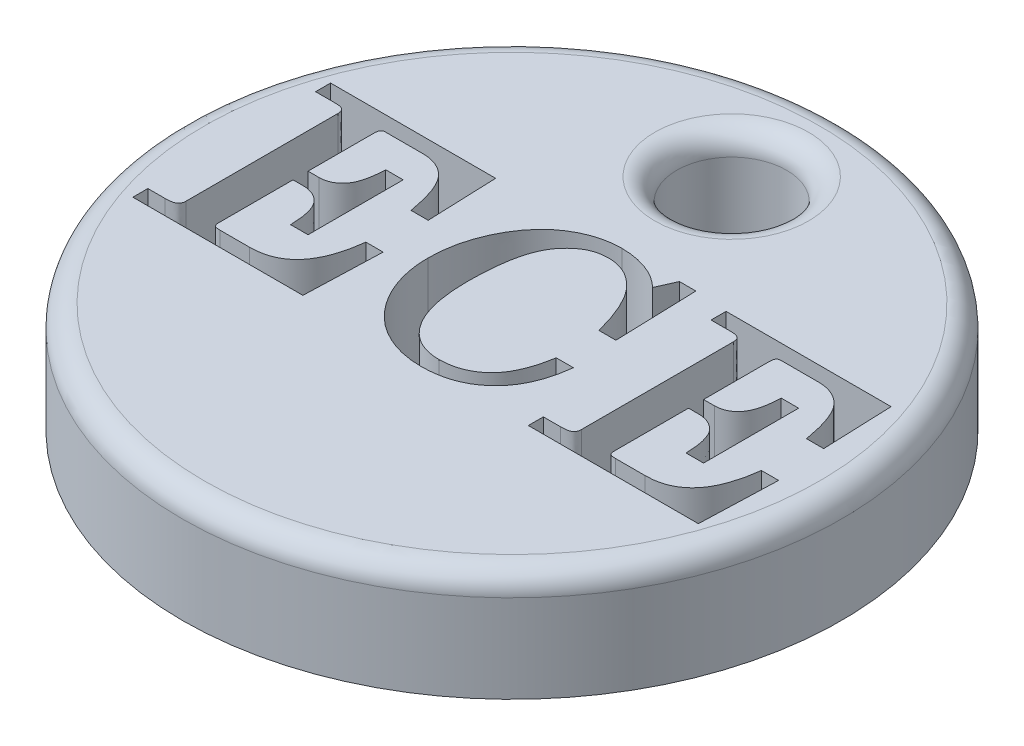
from build123d import *

# Parameters (mm, degrees)
SKETCH1_R           = 15
SKETCH1_R_2         = 2.5
BOSS_EXTRUDE1_DEPTH = 4
SKETCH2_R           = 15
SKETCH2_R_2         = 2.5
BOSS_EXTRUDE2_DEPTH = 1
FILLET1_R           = 1


with BuildPart() as part:
    # Sketch1 → Boss-Extrude1 (new body)
    with BuildSketch(Plane(origin=(0, 0, 0), x_dir=(1, 0, 0), z_dir=(0, 1, 0))):
        Circle(SKETCH1_R)
        with Locations((0, 10)):
            Circle(SKETCH1_R_2, mode=Mode.SUBTRACT)
        with BuildLine():
            Line((-12.816455696, 4.559282851), (-5.304588608, 4.559282851))
            Line((-5.304588608, 4.559282851), (-5.183544304, 1.369409433))
            Line((-5.183544304, 1.369409433), (-5.964992089, 1.369409433))
            add(Edge.make_bspline(
                [(-5.964992089, 1.369409433), (-5.986281307, 1.485829278), (-6.027251179, 1.709872544), (-6.09691097, 2.03065438), (-6.178132694, 2.321858437), (-6.262578433, 2.585270441), (-6.360705102, 2.817779205), (-6.459727152, 3.023988235), (-6.570656541, 3.199818347), (-6.689291162, 3.348294343), (-6.817301446, 3.473270548), (-6.951038881, 3.582226232), (-7.096552563, 3.671938194), (-7.248723792, 3.747265164), (-7.411675737, 3.803812372), (-7.581643533, 3.847718892), (-7.762280373, 3.869850654), (-7.885038619, 3.873742839), (-7.947982595, 3.875738547)],
                knots=[0, 0, 0, 0, 0.000355055, 0.000683282, 0.000984286, 0.001261799, 0.001512378, 0.001740851, 0.001947277, 0.002134649, 0.002309612, 0.002483084, 0.002651015, 0.002821381, 0.002991412, 0.003167557, 0.003347061, 0.003535958, 0.003535958, 0.003535958, 0.003535958], degree=3))
            Line((-7.947982595, 3.875738547), (-9.662183544, 3.875738547))
            add(Edge.make_bspline(
                [(-9.662183544, 3.875738547), (-9.686590299, 3.873079058), (-9.737084073, 3.867576989), (-9.79187547, 3.825290825), (-9.825309008, 3.77193289), (-9.843197408, 3.710763238), (-9.852838206, 3.631011988), (-9.853863138, 3.571978347), (-9.85443038, 3.539306585)],
                knots=[0, 0, 0, 0, 7.2613e-05, 0.000150224, 0.000196643, 0.000260253, 0.000339301, 0.000437269, 0.000437269, 0.000437269, 0.000437269], degree=3))
            Line((-9.85443038, 3.539306585), (-9.85443038, 0.571941079))
            Line((-9.85443038, 0.571941079), (-9.361352848, 0.571941079))
            add(Edge.make_bspline(
                [(-9.361352848, 0.571941079), (-9.318583098, 0.573595492), (-9.234461221, 0.576849482), (-9.111162234, 0.593963395), (-8.993863335, 0.626323435), (-8.884033689, 0.673274803), (-8.778673677, 0.730345716), (-8.680915787, 0.802613326), (-8.588042471, 0.88626065), (-8.501369299, 0.983641568), (-8.422640676, 1.09682009), (-8.352445274, 1.227900491), (-8.29573087, 1.378846708), (-8.242476792, 1.545755817), (-8.205719241, 1.732948279), (-8.172686978, 1.936972787), (-8.152229688, 2.160011542), (-8.145498883, 2.314589472), (-8.142009494, 2.394725889)],
                knots=[0, 0, 0, 0, 0.000128362, 0.00025247, 0.000372528, 0.000492204, 0.000610119, 0.000731176, 0.000855946, 0.000984554, 0.001121342, 0.001268668, 0.001429318, 0.001604426, 0.001793649, 0.002000849, 0.00222438, 0.002465011, 0.002465011, 0.002465011, 0.002465011], degree=3))
            Line((-8.142009494, 2.394725889), (-7.348101266, 2.394725889))
            Line((-7.348101266, 2.394725889), (-7.348101266, -1.934388035))
            Line((-7.348101266, -1.934388035), (-8.142009494, -1.934388035))
            add(Edge.make_bspline(
                [(-8.142009494, -1.934388035), (-8.145486425, -1.850690613), (-8.152178707, -1.689592614), (-8.172633195, -1.458277906), (-8.205193707, -1.247469079), (-8.24418684, -1.057083799), (-8.296876455, -0.887752558), (-8.356286349, -0.738271818), (-8.424893398, -0.607794818), (-8.507041219, -0.500028728), (-8.595368486, -0.407272558), (-8.692551734, -0.329087092), (-8.795830639, -0.26086641), (-8.906633017, -0.204893452), (-9.025654625, -0.164593005), (-9.151322342, -0.134338038), (-9.284720067, -0.113556793), (-9.376699046, -0.112263475), (-9.423655063, -0.111603225)],
                knots=[0, 0, 0, 0, 0.000251298, 0.00048369, 0.000696167, 0.000890985, 0.001066093, 0.001227402, 0.001373161, 0.001506666, 0.00163256, 0.001756553, 0.001879982, 0.002003373, 0.002127786, 0.002256013, 0.002390946, 0.002531672, 0.002531672, 0.002531672, 0.002531672], degree=3))
            Line((-9.423655063, -0.111603225), (-9.85443038, -0.111603225))
            Line((-9.85443038, -0.111603225), (-9.85443038, -3.479482972))
            add(Edge.make_bspline(
                [(-9.85443038, -3.479482972), (-9.854381112, -3.50574702), (-9.854290593, -3.554001322), (-9.838365834, -3.618020738), (-9.821636658, -3.671107598), (-9.787878561, -3.708056504), (-9.742813823, -3.732221482), (-9.684974169, -3.7469717), (-9.613168799, -3.755068374), (-9.560744488, -3.756431597), (-9.532238924, -3.757172845)],
                knots=[0, 0, 0, 0, 7.8404e-05, 0.000144049, 0.000197599, 0.000242982, 0.000290011, 0.000349183, 0.000420939, 0.000506457, 0.000506457, 0.000506457, 0.000506457], degree=3))
            Line((-9.532238924, -3.757172845), (-8.179390823, -3.757172845))
            add(Edge.make_bspline(
                [(-8.179390823, -3.757172845), (-8.093820738, -3.755405593), (-7.92672034, -3.75195452), (-7.683560133, -3.716779904), (-7.453538807, -3.662313942), (-7.237993715, -3.583902551), (-7.035823491, -3.483354545), (-6.848551686, -3.359142306), (-6.672461464, -3.215322738), (-6.514171578, -3.045304637), (-6.366924413, -2.856023595), (-6.235681121, -2.643037993), (-6.118228598, -2.407990645), (-6.012943956, -2.15190931), (-5.924840371, -1.872157778), (-5.849132979, -1.571285989), (-5.783475169, -1.2484377), (-5.755241294, -1.024416559), (-5.740704114, -0.90907158)],
                knots=[0, 0, 0, 0, 0.000256552, 0.000500991, 0.000735426, 0.000964612, 0.001187512, 0.001411163, 0.001637483, 0.00186791, 0.002106465, 0.002355909, 0.002617021, 0.002894031, 0.003185636, 0.003496051, 0.003824554, 0.004173215, 0.004173215, 0.004173215, 0.004173215], degree=3))
            Line((-5.740704114, -0.90907158), (-4.955696203, -0.90907158))
            Line((-4.955696203, -0.90907158), (-5.076740506, -4.440717149))
            Line((-5.076740506, -4.440717149), (-12.816455696, -4.440717149))
            Line((-12.816455696, -4.440717149), (-12.816455696, -3.757172845))
            Line((-12.816455696, -3.757172845), (-12.038568038, -3.757172845))
            add(Edge.make_bspline(
                [(-12.038568038, -3.757172845), (-11.985118982, -3.756473559), (-11.886759814, -3.755186702), (-11.753911012, -3.738537224), (-11.649119675, -3.710930668), (-11.568974594, -3.67243269), (-11.514731814, -3.616493802), (-11.476958428, -3.552979196), (-11.452127266, -3.478862951), (-11.450321619, -3.425702573), (-11.449367089, -3.397600061)],
                knots=[0, 0, 0, 0, 0.000160295, 0.000294981, 0.000400366, 0.000484764, 0.000557769, 0.000630425, 0.000705293, 0.000789259, 0.000789259, 0.000789259, 0.000789259], degree=3))
            Line((-11.449367089, -3.397600061), (-11.449367089, 3.533966395))
            add(Edge.make_bspline(
                [(-11.449367089, 3.533966395), (-11.450938449, 3.56133357), (-11.453912967, 3.613138472), (-11.470496787, 3.686102732), (-11.503361955, 3.746902252), (-11.550862663, 3.79569976), (-11.613347248, 3.834241454), (-11.695492555, 3.857523729), (-11.794661361, 3.873421993), (-11.867598111, 3.874928134), (-11.906843354, 3.875738547)],
                knots=[0, 0, 0, 0, 8.2192e-05, 0.000155586, 0.000222498, 0.000286704, 0.00035784, 0.000440032, 0.000540994, 0.0006586, 0.0006586, 0.0006586, 0.0006586], degree=3))
            Line((-11.906843354, 3.875738547), (-12.816455696, 3.875738547))
            Line((-12.816455696, 3.875738547), (-12.816455696, 4.559282851))
        make_face(mode=Mode.SUBTRACT)
        with BuildLine():
            Line((2.570411392, 3.829456901), (2.94778481, 4.673206901))
            Line((2.94778481, 4.673206901), (3.695411392, 4.673206901))
            Line((3.695411392, 4.673206901), (3.816455696, 0.913713231))
            Line((3.816455696, 0.913713231), (3.043908228, 0.913713231))
            add(Edge.make_bspline(
                [(3.043908228, 0.913713231), (3.009497834, 1.037889271), (2.942713098, 1.278893901), (2.835950602, 1.626082968), (2.718521773, 1.945135777), (2.601588886, 2.239469713), (2.47458714, 2.505364291), (2.343064233, 2.744523794), (2.207289141, 2.958253793), (2.106299883, 3.084989338), (2.057753165, 3.145912598)],
                knots=[0, 0, 0, 0, 0.000386573, 0.000750273, 0.001089261, 0.001406263, 0.001700065, 0.001972548, 0.002224853, 0.002458415, 0.002458415, 0.002458415, 0.002458415], degree=3))
            add(Edge.make_bspline(
                [(2.057753165, 3.145912598), (1.999150424, 3.213044608), (1.884702933, 3.344149229), (1.694048964, 3.515618841), (1.496781165, 3.661681522), (1.292280185, 3.784119941), (1.077016312, 3.87408879), (0.85454424, 3.940392619), (0.62409651, 3.98356997), (0.467160324, 3.987620736), (0.388053797, 3.989662598)],
                knots=[0, 0, 0, 0, 0.00026714, 0.000521708, 0.000767363, 0.001002742, 0.001234841, 0.001465185, 0.001698435, 0.001935511, 0.001935511, 0.001935511, 0.001935511], degree=3))
            add(Edge.make_bspline(
                [(0.388053797, 3.989662598), (0.310121094, 3.986977635), (0.155441044, 3.981648547), (-0.071335373, 3.937423427), (-0.289382677, 3.866804644), (-0.495246243, 3.762167459), (-0.694859522, 3.634615804), (-0.881375299, 3.47350318), (-1.060743278, 3.286905309), (-1.23146115, 3.070735691), (-1.386226621, 2.816496369), (-1.518891265, 2.519573628), (-1.631831347, 2.180224344), (-1.723541519, 1.797194342), (-1.792883043, 1.371067856), (-1.844117264, 0.902301932), (-1.873718313, 0.390162426), (-1.877683201, 0.03440106), (-1.879746835, -0.150764618)],
                knots=[0, 0, 0, 0, 0.000233623, 0.000463692, 0.000690544, 0.000919017, 0.001154531, 0.001399546, 0.001656369, 0.00193021, 0.002224201, 0.00254683, 0.002903714, 0.003295732, 0.003727084, 0.004198078, 0.004709852, 0.005265334, 0.005265334, 0.005265334, 0.005265334], degree=3))
            add(Edge.make_bspline(
                [(-1.879746835, -0.150764618), (-1.878194357, -0.307494053), (-1.875184992, -0.611302438), (-1.837912486, -1.051560799), (-1.783043986, -1.461574808), (-1.702652086, -1.841150378), (-1.601389229, -2.190335587), (-1.473400233, -2.508059277), (-1.326727186, -2.797479907), (-1.204282585, -2.968756332), (-1.144580696, -3.052267782)],
                knots=[0, 0, 0, 0, 0.000470058, 0.000911173, 0.001324531, 0.001710312, 0.00207416, 0.002413634, 0.002736886, 0.003044472, 0.003044472, 0.003044472, 0.003044472], degree=3))
            add(Edge.make_bspline(
                [(-1.144580696, -3.052267782), (-1.090880158, -3.117709519), (-0.985725592, -3.245855302), (-0.805294932, -3.411980731), (-0.613701933, -3.5544281), (-0.407766387, -3.671302533), (-0.18712895, -3.760124711), (0.046334616, -3.824285822), (0.292896582, -3.864756775), (0.462064567, -3.868956858), (0.548259494, -3.871096896)],
                knots=[0, 0, 0, 0, 0.000253701, 0.000496789, 0.000733544, 0.000968688, 0.001205034, 0.001445152, 0.001693902, 0.001952312, 0.001952312, 0.001952312, 0.001952312], degree=3))
            add(Edge.make_bspline(
                [(0.548259494, -3.871096896), (0.630841372, -3.869026621), (0.793009204, -3.864961177), (1.030566333, -3.833520863), (1.258517532, -3.785400281), (1.474293584, -3.710019598), (1.682367574, -3.620516487), (1.87857324, -3.507096939), (2.065242345, -3.37433122), (2.241653776, -3.221090808), (2.407060972, -3.045652507), (2.556724651, -2.844592976), (2.692146878, -2.619004834), (2.812585748, -2.368993897), (2.91917543, -2.095706479), (3.011756663, -1.79831301), (3.089874113, -1.476570226), (3.128871857, -1.252288355), (3.148931962, -1.136919681)],
                knots=[0, 0, 0, 0, 0.000247659, 0.000486334, 0.000717831, 0.000945248, 0.00117081, 0.001396458, 0.001623665, 0.001857098, 0.002096369, 0.002345578, 0.002607507, 0.002884558, 0.003177101, 0.00348675, 0.003818324, 0.004169552, 0.004169552, 0.004169552, 0.004169552], degree=3))
            Line((3.148931962, -1.136919681), (3.930379747, -1.136919681))
            add(Edge.make_bspline(
                [(3.930379747, -1.136919681), (3.912693645, -1.271920971), (3.878130861, -1.535745109), (3.795807435, -1.916532895), (3.691382286, -2.27356458), (3.56129363, -2.604363974), (3.409903214, -2.912161039), (3.232903343, -3.193452172), (3.03496662, -3.452596142), (2.811815267, -3.683716781), (2.569038755, -3.888570505), (2.310309664, -4.067958976), (2.03417364, -4.217872277), (1.74212339, -4.341396003), (1.432843588, -4.438134016), (1.106481419, -4.504236875), (0.764165068, -4.546650481), (0.53058836, -4.551938306), (0.41119462, -4.5546412)],
                knots=[0, 0, 0, 0, 0.000408322, 0.000797957, 0.00116743, 0.001523109, 0.001863031, 0.00219493, 0.002518574, 0.002839603, 0.003156639, 0.003470178, 0.003782436, 0.004097512, 0.004420116, 0.004752817, 0.005095265, 0.005453341, 0.005453341, 0.005453341, 0.005453341], degree=3))
            add(Edge.make_bspline(
                [(0.41119462, -4.5546412), (0.317965184, -4.553022456), (0.133492258, -4.549819451), (-0.139867753, -4.521478839), (-0.407097372, -4.479868052), (-0.668151695, -4.418754419), (-0.923364143, -4.340401407), (-1.172285152, -4.243973114), (-1.415765271, -4.131532079), (-1.651735997, -4.001658104), (-1.879708517, -3.856447035), (-2.095760079, -3.693332319), (-2.300458477, -3.515566332), (-2.492973492, -3.322153053), (-2.675561159, -3.115648405), (-2.844272331, -2.892577995), (-3.001554486, -2.654592377), (-3.146340716, -2.403043508), (-3.278664524, -2.141220839), (-3.389606773, -1.869589869), (-3.486844536, -1.593714937), (-3.564555382, -1.310977935), (-3.628334, -1.022528199), (-3.669198625, -0.72661494), (-3.697736536, -0.424858118), (-3.700922716, -0.221442552), (-3.702531646, -0.118723478)],
                knots=[0, 0, 0, 0, 0.000279612, 0.000553267, 0.000823673, 0.001090516, 0.001356842, 0.001623947, 0.001890748, 0.002160814, 0.002431407, 0.002700909, 0.002972186, 0.003244064, 0.003519025, 0.0037985, 0.00408238, 0.004374267, 0.004668812, 0.004961702, 0.005253876, 0.005545828, 0.005840852, 0.006139415, 0.006441428, 0.006749508, 0.006749508, 0.006749508, 0.006749508], degree=3))
            add(Edge.make_bspline(
                [(-3.702531646, -0.118723478), (-3.700764656, -0.010095108), (-3.697244652, 0.206302537), (-3.670707193, 0.528064994), (-3.622928391, 0.844416256), (-3.562067832, 1.156396727), (-3.479325367, 1.462847999), (-3.379201107, 1.764636267), (-3.262323042, 2.061561461), (-3.126942162, 2.350508628), (-2.978820805, 2.628272947), (-2.818506799, 2.890518249), (-2.647636587, 3.135163907), (-2.465621468, 3.361134359), (-2.275075212, 3.57139288), (-2.071617656, 3.761137611), (-1.859407338, 3.935184773), (-1.636769345, 4.089489275), (-1.407032968, 4.226530999), (-1.172460156, 4.346361417), (-0.932076367, 4.445839403), (-0.688837442, 4.530293753), (-0.440619993, 4.594794066), (-0.188040769, 4.638117838), (0.068081803, 4.668743302), (0.240811026, 4.671714952), (0.327531646, 4.673206901)],
                knots=[0, 0, 0, 0, 0.000325873, 0.000649169, 0.000967621, 0.001285302, 0.001602233, 0.001919149, 0.002238793, 0.002558932, 0.002875889, 0.003182706, 0.003480488, 0.003770441, 0.00405267, 0.004330981, 0.004604265, 0.004875361, 0.005142786, 0.005406289, 0.00566481, 0.00592263, 0.006178223, 0.006433126, 0.006691033, 0.006951074, 0.006951074, 0.006951074, 0.006951074], degree=3))
            add(Edge.make_bspline(
                [(0.327531646, 4.673206901), (0.430879069, 4.670789554), (0.636472376, 4.665980624), (0.941612696, 4.628023418), (1.24032709, 4.563186293), (1.532443024, 4.474411313), (1.816180044, 4.360480202), (2.084057683, 4.212061957), (2.339756713, 4.038625091), (2.493043976, 3.899617206), (2.570411392, 3.829456901)],
                knots=[0, 0, 0, 0, 0.000309982, 0.000616659, 0.000920758, 0.001225955, 0.001531722, 0.001836024, 0.002143146, 0.002456123, 0.002456123, 0.002456123, 0.002456123], degree=3))
        make_face(mode=Mode.SUBTRACT)
        with BuildLine():
            Line((5.183544304, 4.559282851), (12.695411392, 4.559282851))
            Line((12.695411392, 4.559282851), (12.816455696, 1.369409433))
            Line((12.816455696, 1.369409433), (12.035007911, 1.369409433))
            add(Edge.make_bspline(
                [(12.035007911, 1.369409433), (12.013718693, 1.485829278), (11.972748821, 1.709872544), (11.90308903, 2.03065438), (11.821867306, 2.321858437), (11.737421567, 2.585270441), (11.639294898, 2.817779205), (11.540272848, 3.023988235), (11.429343459, 3.199818347), (11.310708838, 3.348294343), (11.182698554, 3.473270548), (11.048961119, 3.582226232), (10.903447437, 3.671938194), (10.751276208, 3.747265164), (10.588324263, 3.803812372), (10.418356467, 3.847718892), (10.237719627, 3.869850654), (10.114961381, 3.873742839), (10.052017405, 3.875738547)],
                knots=[0, 0, 0, 0, 0.000355055, 0.000683282, 0.000984286, 0.001261799, 0.001512378, 0.001740851, 0.001947277, 0.002134649, 0.002309612, 0.002483084, 0.002651015, 0.002821381, 0.002991412, 0.003167557, 0.003347061, 0.003535958, 0.003535958, 0.003535958, 0.003535958], degree=3))
            Line((10.052017405, 3.875738547), (8.337816456, 3.875738547))
            add(Edge.make_bspline(
                [(8.337816456, 3.875738547), (8.313409701, 3.873079058), (8.262915927, 3.867576989), (8.20812453, 3.825290825), (8.174690992, 3.77193289), (8.156802592, 3.710763238), (8.147161794, 3.631011988), (8.146136862, 3.571978347), (8.14556962, 3.539306585)],
                knots=[0, 0, 0, 0, 7.2613e-05, 0.000150224, 0.000196643, 0.000260253, 0.000339301, 0.000437269, 0.000437269, 0.000437269, 0.000437269], degree=3))
            Line((8.14556962, 3.539306585), (8.14556962, 0.571941079))
            Line((8.14556962, 0.571941079), (8.638647152, 0.571941079))
            add(Edge.make_bspline(
                [(8.638647152, 0.571941079), (8.681416902, 0.573595492), (8.765538779, 0.576849482), (8.888837766, 0.593963395), (9.006136665, 0.626323435), (9.115966311, 0.673274803), (9.221326323, 0.730345716), (9.319084213, 0.802613326), (9.411957529, 0.88626065), (9.498630701, 0.983641568), (9.577359324, 1.09682009), (9.647554726, 1.227900491), (9.70426913, 1.378846708), (9.757523208, 1.545755817), (9.794280759, 1.732948279), (9.827313022, 1.936972787), (9.847770312, 2.160011542), (9.854501117, 2.314589472), (9.857990506, 2.394725889)],
                knots=[0, 0, 0, 0, 0.000128362, 0.00025247, 0.000372528, 0.000492204, 0.000610119, 0.000731176, 0.000855946, 0.000984554, 0.001121342, 0.001268668, 0.001429318, 0.001604426, 0.001793649, 0.002000849, 0.00222438, 0.002465011, 0.002465011, 0.002465011, 0.002465011], degree=3))
            Line((9.857990506, 2.394725889), (10.651898734, 2.394725889))
            Line((10.651898734, 2.394725889), (10.651898734, -1.934388035))
            Line((10.651898734, -1.934388035), (9.857990506, -1.934388035))
            add(Edge.make_bspline(
                [(9.857990506, -1.934388035), (9.854513575, -1.850690613), (9.847821293, -1.689592614), (9.827366805, -1.458277906), (9.794806293, -1.247469079), (9.75581316, -1.057083799), (9.703123545, -0.887752558), (9.643713651, -0.738271818), (9.575106602, -0.607794818), (9.492958781, -0.500028728), (9.404631514, -0.407272558), (9.307448266, -0.329087092), (9.204169361, -0.26086641), (9.093366983, -0.204893452), (8.974345375, -0.164593005), (8.848677658, -0.134338038), (8.715279933, -0.113556793), (8.623300954, -0.112263475), (8.576344937, -0.111603225)],
                knots=[0, 0, 0, 0, 0.000251298, 0.00048369, 0.000696167, 0.000890985, 0.001066093, 0.001227402, 0.001373161, 0.001506666, 0.00163256, 0.001756553, 0.001879982, 0.002003373, 0.002127786, 0.002256013, 0.002390946, 0.002531672, 0.002531672, 0.002531672, 0.002531672], degree=3))
            Line((8.576344937, -0.111603225), (8.14556962, -0.111603225))
            Line((8.14556962, -0.111603225), (8.14556962, -3.479482972))
            add(Edge.make_bspline(
                [(8.14556962, -3.479482972), (8.145618888, -3.50574702), (8.145709407, -3.554001322), (8.161634166, -3.618020738), (8.178363342, -3.671107598), (8.212121439, -3.708056504), (8.257186177, -3.732221482), (8.315025831, -3.7469717), (8.386831201, -3.755068374), (8.439255512, -3.756431597), (8.467761076, -3.757172845)],
                knots=[0, 0, 0, 0, 7.8404e-05, 0.000144049, 0.000197599, 0.000242982, 0.000290011, 0.000349183, 0.000420939, 0.000506457, 0.000506457, 0.000506457, 0.000506457], degree=3))
            Line((8.467761076, -3.757172845), (9.820609177, -3.757172845))
            add(Edge.make_bspline(
                [(9.820609177, -3.757172845), (9.906179262, -3.755405593), (10.07327966, -3.75195452), (10.316439867, -3.716779904), (10.546461193, -3.662313942), (10.762006285, -3.583902551), (10.964176509, -3.483354545), (11.151448314, -3.359142306), (11.327538536, -3.215322738), (11.485828422, -3.045304637), (11.633075587, -2.856023595), (11.764318879, -2.643037993), (11.881771402, -2.407990645), (11.987056044, -2.15190931), (12.075159629, -1.872157778), (12.150867021, -1.571285989), (12.216524831, -1.2484377), (12.244758706, -1.024416559), (12.259295886, -0.90907158)],
                knots=[0, 0, 0, 0, 0.000256552, 0.000500991, 0.000735426, 0.000964612, 0.001187512, 0.001411163, 0.001637483, 0.00186791, 0.002106465, 0.002355909, 0.002617021, 0.002894031, 0.003185636, 0.003496051, 0.003824554, 0.004173215, 0.004173215, 0.004173215, 0.004173215], degree=3))
            Line((12.259295886, -0.90907158), (13.044303797, -0.90907158))
            Line((13.044303797, -0.90907158), (12.923259494, -4.440717149))
            Line((12.923259494, -4.440717149), (5.183544304, -4.440717149))
            Line((5.183544304, -4.440717149), (5.183544304, -3.757172845))
            Line((5.183544304, -3.757172845), (5.961431962, -3.757172845))
            add(Edge.make_bspline(
                [(5.961431962, -3.757172845), (6.014881018, -3.756473559), (6.113240186, -3.755186702), (6.246088988, -3.738537224), (6.350880325, -3.710930668), (6.431025406, -3.67243269), (6.485268186, -3.616493802), (6.523041572, -3.552979196), (6.547872734, -3.478862951), (6.549678381, -3.425702573), (6.550632911, -3.397600061)],
                knots=[0, 0, 0, 0, 0.000160295, 0.000294981, 0.000400366, 0.000484764, 0.000557769, 0.000630425, 0.000705293, 0.000789259, 0.000789259, 0.000789259, 0.000789259], degree=3))
            Line((6.550632911, -3.397600061), (6.550632911, 3.533966395))
            add(Edge.make_bspline(
                [(6.550632911, 3.533966395), (6.549061551, 3.56133357), (6.546087033, 3.613138472), (6.529503213, 3.686102732), (6.496638045, 3.746902252), (6.449137337, 3.79569976), (6.386652752, 3.834241454), (6.304507445, 3.857523729), (6.205338639, 3.873421993), (6.132401889, 3.874928134), (6.093156646, 3.875738547)],
                knots=[0, 0, 0, 0, 8.2192e-05, 0.000155586, 0.000222498, 0.000286704, 0.00035784, 0.000440032, 0.000540994, 0.0006586, 0.0006586, 0.0006586, 0.0006586], degree=3))
            Line((6.093156646, 3.875738547), (5.183544304, 3.875738547))
            Line((5.183544304, 3.875738547), (5.183544304, 4.559282851))
        make_face(mode=Mode.SUBTRACT)
    extrude(amount=BOSS_EXTRUDE1_DEPTH)

    # Sketch2 → Boss-Extrude2 (add)
    with BuildSketch(Plane.XZ):
        Circle(SKETCH2_R)
        with Locations((0, -10)):
            Circle(SKETCH2_R_2, mode=Mode.SUBTRACT)
    extrude(amount=BOSS_EXTRUDE2_DEPTH)

    # Fillet1
    fillet1_edges = [part.edges().sort_by_distance(p)[0] for p in [
        (-2.5, 4, -10),
        (-15, 4, 0),
    ]]
    fillet(fillet1_edges, radius=FILLET1_R)


solid = part.part
